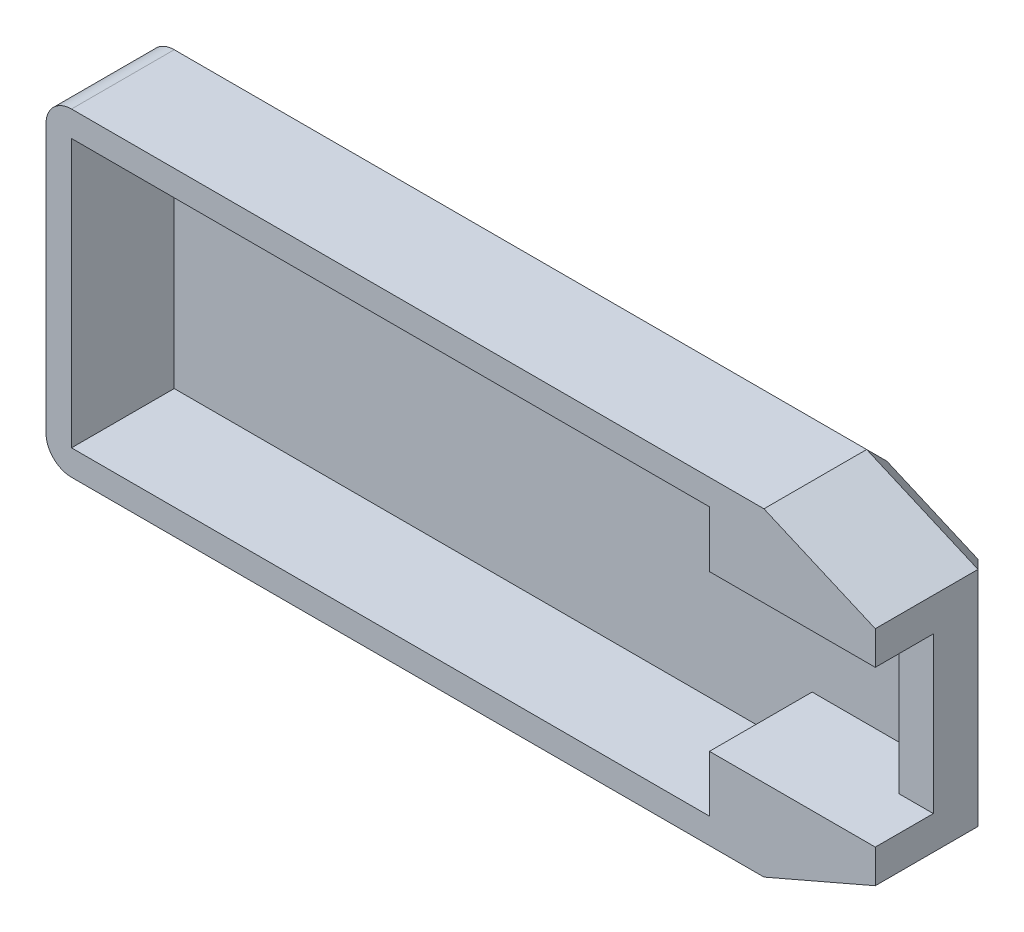
from build123d import *

# Parameters (mm, degrees)
EXTRUDE_1_DEPTH = 2
EXTRUDE_2_DEPTH = 3.5
EXTRUDE_3_DEPTH = 4.55
FILLET_1_R      = 2
CHAMFER_1_SIZE  = 2
CHAMFER_2_SIZE  = 2


with BuildPart() as part:
    # Эскиз1 → Бобышка-Вытянуть1 (new body)
    with BuildSketch(Plane.XY):
        Polygon((46.296875, 9.92578125), (37.5703125, 13.70078125), (-18.703125, 13.70078125), (-18.703125, -11.29921875), (37.5703125, -11.29921875), (46.296875, -7.52421875), align=None)
    extrude(amount=EXTRUDE_1_DEPTH)

    # Эскиз2 → Бобышка-Вытянуть2 (add)
    with BuildSketch(Plane.XY.offset(2)):
        Polygon((-18.703125, -11.29921875), (37.5703125, -11.29921875), (46.296875, -7.52421875), (46.296875, 9.92578125), (37.5703125, 13.70078125), (-18.703125, 13.70078125), align=None)
        Polygon((-16.703125, 11.70078125), (33.296875, 11.70078125), (33.296875, 7.30078125), (43.596875, 7.30078125), (43.596875, -4.89921875), (33.296875, -4.89921875), (33.296875, -9.29921875), (-16.703125, -9.29921875), align=None, mode=Mode.SUBTRACT)
    extrude(amount=EXTRUDE_2_DEPTH)

    # Эскиз3 → Бобышка-Вытянуть3 (add)
    with BuildSketch(Plane.XY.offset(5.5)):
        Polygon((-18.703125, 13.70078125), (-18.703125, -11.29921875), (37.5703125, -11.29921875), (46.296875, -7.52421875), (46.296875, -4.89921875), (33.296875, -4.89921875), (33.296875, -9.29921875), (-16.703125, -9.29921875), (-16.703125, 11.70078125), (33.296875, 11.70078125), (33.296875, 7.30078125), (46.296875, 7.30078125), (46.296875, 9.92578125), (37.5703125, 13.70078125), align=None)
    extrude(amount=EXTRUDE_3_DEPTH)

    # Скругление1
    fillet_1_edges = [part.edges().sort_by_distance(p)[0] for p in [
        (-18.703125, 13.70078125, 5.025),
        (-18.703125, -11.29921875, 5.025),
    ]]
    fillet(fillet_1_edges, radius=FILLET_1_R)

    # Фаска1
    chamfer_1_edges = [part.edges().sort_by_distance(p)[0] for p in [
        (10.43359375, 13.70078125, 0),
        (10.43359375, -11.29921875, 0),
        (-18.703125, 1.20078125, 0),
        (-18.117338562, 13.114994812, 0),
        (-18.117338562, -10.713432312, 0),
    ]]
    chamfer(chamfer_1_edges, length=CHAMFER_1_SIZE)

    # Фаска2
    chamfer_2_edges = [part.edges().sort_by_distance(p)[0] for p in [
        (44.245265935, 10.81328125, 0),
        (46.296875, 1.20078125, 0),
        (44.245265935, -8.41171875, 0),
    ]]
    chamfer(chamfer_2_edges, length=CHAMFER_2_SIZE)


solid = part.part
